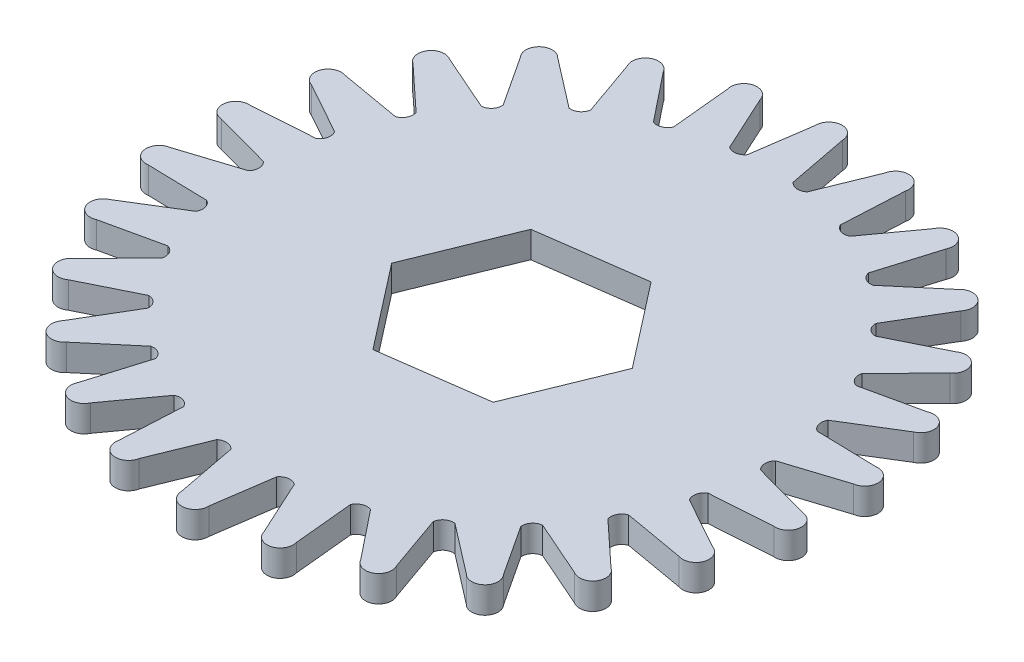
from build123d import *

# Parameters (mm, degrees)
EXTRUDE_1_DEPTH = 2


with BuildPart() as part:
    # Эскиз1 → Бобышка-Вытянуть1 (new body)
    with BuildSketch(Plane(origin=(0, 0, 0), x_dir=(1, 0, 0), z_dir=(0, 1, 0))):
        with BuildLine():
            Line((-0.999103612, 23.957668294), (-1.653583768, 19.471915792))
            ThreePointArc((-1.653583768, 19.471915792), (-2.196840792, 19.142290441), (-2.813399675, 19.29603117))
            Line((-2.813399675, 19.29603117), (-4.78072656, 23.572642625))
            ThreePointArc((-4.78072656, 23.572642625), (-6.018700674, 24.264012159), (-6.703516779, 23.02240085))
            Line((-6.703516779, 23.02240085), (-6.265468091, 18.51036881))
            ThreePointArc((-6.265468091, 18.51036881), (-6.714054544, 18.060311857), (-7.349489911, 18.062032961))
            Line((-7.349489911, 18.062032961), (-10.283109963, 21.743561719))
            ThreePointArc((-10.283109963, 21.743561719), (-11.650566359, 22.118574714), (-12.018345917, 20.749155152))
            Line((-12.018345917, 20.749155152), (-10.513226184, 16.473066476))
            ThreePointArc((-10.513226184, 16.473066476), (-10.841071851, 15.928733595), (-11.458454507, 15.77833505))
            Line((-11.458454507, 15.77833505), (-15.187876393, 18.650824041))
            ThreePointArc((-15.187876393, 18.650824041), (-16.605343475, 18.687686104), (-16.634712476, 17.270043976))
            Line((-16.634712476, 17.270043976), (-14.149993784, 13.478409394))
            ThreePointArc((-14.149993784, 13.478409394), (-14.338045467, 12.871435234), (-14.901495378, 12.577657657))
            Line((-14.901495378, 12.577657657), (-19.209978653, 14.474168263))
            ThreePointArc((-19.209978653, 14.474168263), (-20.595078387, 14.170737105), (-20.28433001, 12.787260619))
            Line((-20.28433001, 12.787260619), (-16.964415179, 9.700436151))
            ThreePointArc((-16.964415179, 9.700436151), (-17.001743998, 9.066095843), (-17.478515502, 8.646012519))
            Line((-17.478515502, 8.646012519), (-22.115666779, 9.456326437))
            ThreePointArc((-22.115666779, 9.456326437), (-23.387902203, 8.830236374), (-22.755096015, 7.561328154))
            Line((-22.755096015, 7.561328154), (-18.792926427, 5.358708819))
            ThreePointArc((-18.792926427, 5.358708819), (-18.677362966, 4.733867916), (-19.039747837, 4.211892561))
            Line((-19.039747837, 4.211892561), (-23.736072739, 3.88891729))
            ThreePointArc((-23.736072739, 3.88891729), (-24.821506154, 2.976554401), (-23.90341855, 1.895958781))
            Line((-23.90341855, 1.895958781), (-19.529261101, 0.705552808))
            ThreePointArc((-19.529261101, 0.705552808), (-19.267521488, 0.126524793), (-19.494459234, -0.467007284))
            Line((-19.494459234, -0.467007284), (-23.977024428, -1.904501593))
            ThreePointArc((-23.977024428, -1.904501593), (-24.81257439, -3.050114094), (-23.662561285, -3.879596824))
            Line((-23.662561285, -3.879596824), (-19.130626105, -3.988607368))
            ThreePointArc((-19.130626105, -3.988607368), (-18.737921695, -4.488171492), (-18.81622352, -5.118766363))
            Line((-18.81622352, -5.118766363), (-22.824518611, -7.587237767))
            ThreePointArc((-22.824518611, -7.587237767), (-23.361625993, -8.899521045), (-22.046521968, -9.429684364))
            Line((-22.046521968, -9.429684364), (-17.620188657, -8.450964181))
            ThreePointArc((-17.620188657, -8.450964181), (-17.119342004, -8.842031563), (-17.044457289, -9.473041346))
            Line((-17.044457289, -9.473041346), (-20.345534735, -12.82903126))
            ThreePointArc((-20.345534735, -12.82903126), (-20.552984809, -14.231720181), (-19.14921893, -14.431752924))
            Line((-19.14921893, -14.431752924), (-15.085729891, -12.422181675))
            ThreePointArc((-15.085729891, -12.422181675), (-14.505848381, -12.682024899), (-14.282129155, -13.2767776))
            Line((-14.282129155, -13.2767776), (-16.684142334, -17.325248088))
            ThreePointArc((-16.684142334, -17.325248088), (-16.549878855, -18.73682347), (-15.139032892, -18.595100462))
            Line((-15.139032892, -18.595100462), (-11.674543338, -15.671467122))
            ThreePointArc((-11.674543338, -15.671467122), (-11.049327577, -15.784985046), (-10.689775588, -16.308915799))
            Line((-10.689775588, -16.308915799), (-12.053128225, -20.814584472))
            ThreePointArc((-12.053128225, -20.814584472), (-11.584954098, -22.153010685), (-10.249021291, -21.677768351))
            Line((-10.249021291, -21.677768351), (-7.584874762, -18.009983863))
            ThreePointArc((-7.584874762, -18.009983863), (-6.950660017, -17.970579237), (-6.476171119, -18.393239092))
            Line((-6.476171119, -18.393239092), (-6.721630115, -23.094252864))
            ThreePointArc((-6.721630115, -23.094252864), (-5.946753919, -24.281745441), (-4.763373826, -23.500603139))
            Line((-4.763373826, -23.500603139), (-3.054400834, -19.301825806))
            ThreePointArc((-3.054400834, -19.301825806), (-2.448045361, -19.111788684), (-1.886195124, -19.408614185))
            Line((-1.886195124, -19.408614185), (-0.999495294, -24.031767224))
            ThreePointArc((-0.999495294, -24.031767224), (0.037049983, -24.999313414), (0.999103612, -23.957668294))
            Line((0.999103612, -23.957668294), (1.653583768, -19.471915792))
            ThreePointArc((1.653583768, -19.471915792), (2.196840792, -19.142290441), (2.813399675, -19.29603117))
            Line((2.813399675, -19.29603117), (4.78072656, -23.572642625))
            ThreePointArc((4.78072656, -23.572642625), (6.018700674, -24.264012159), (6.703516779, -23.02240085))
            Line((6.703516779, -23.02240085), (6.265468091, -18.51036881))
            ThreePointArc((6.265468091, -18.51036881), (6.714054544, -18.060311857), (7.349489911, -18.062032961))
            Line((7.349489911, -18.062032961), (10.283109963, -21.743561719))
            ThreePointArc((10.283109963, -21.743561719), (11.650566359, -22.118574714), (12.018345917, -20.749155152))
            Line((12.018345917, -20.749155152), (10.513226184, -16.473066476))
            ThreePointArc((10.513226184, -16.473066476), (10.841071851, -15.928733595), (11.458454507, -15.77833505))
            Line((11.458454507, -15.77833505), (15.187876393, -18.650824041))
            ThreePointArc((15.187876393, -18.650824041), (16.605343475, -18.687686104), (16.634712476, -17.270043976))
            Line((16.634712476, -17.270043976), (14.149993784, -13.478409394))
            ThreePointArc((14.149993784, -13.478409394), (14.338045467, -12.871435234), (14.901495378, -12.577657657))
            Line((14.901495378, -12.577657657), (19.209978653, -14.474168263))
            ThreePointArc((19.209978653, -14.474168263), (20.595078387, -14.170737105), (20.28433001, -12.787260619))
            Line((20.28433001, -12.787260619), (16.964415179, -9.700436151))
            ThreePointArc((16.964415179, -9.700436151), (17.001743998, -9.066095843), (17.478515502, -8.646012519))
            Line((17.478515502, -8.646012519), (22.115666779, -9.456326437))
            ThreePointArc((22.115666779, -9.456326437), (23.387902203, -8.830236374), (22.755096015, -7.561328154))
            Line((22.755096015, -7.561328154), (18.792926427, -5.358708819))
            ThreePointArc((18.792926427, -5.358708819), (18.677362966, -4.733867916), (19.039747837, -4.211892561))
            Line((19.039747837, -4.211892561), (23.736072739, -3.88891729))
            ThreePointArc((23.736072739, -3.88891729), (24.821506154, -2.976554401), (23.90341855, -1.895958781))
            Line((23.90341855, -1.895958781), (19.529261101, -0.705552808))
            ThreePointArc((19.529261101, -0.705552808), (19.267521488, -0.126524793), (19.494459234, 0.467007284))
            Line((19.494459234, 0.467007284), (23.977024428, 1.904501593))
            ThreePointArc((23.977024428, 1.904501593), (24.81257439, 3.050114094), (23.662561285, 3.879596824))
            Line((23.662561285, 3.879596824), (19.130626105, 3.988607368))
            ThreePointArc((19.130626105, 3.988607368), (18.737921695, 4.488171492), (18.81622352, 5.118766363))
            Line((18.81622352, 5.118766363), (22.824518611, 7.587237767))
            ThreePointArc((22.824518611, 7.587237767), (23.361625993, 8.899521045), (22.046521968, 9.429684364))
            Line((22.046521968, 9.429684364), (17.620188657, 8.450964181))
            ThreePointArc((17.620188657, 8.450964181), (17.119342004, 8.842031563), (17.044457289, 9.473041346))
            Line((17.044457289, 9.473041346), (20.345534735, 12.82903126))
            ThreePointArc((20.345534735, 12.82903126), (20.552984809, 14.231720181), (19.14921893, 14.431752924))
            Line((19.14921893, 14.431752924), (15.085729891, 12.422181675))
            ThreePointArc((15.085729891, 12.422181675), (14.505848381, 12.682024899), (14.282129155, 13.2767776))
            Line((14.282129155, 13.2767776), (16.684142334, 17.325248088))
            ThreePointArc((16.684142334, 17.325248088), (16.549878855, 18.73682347), (15.139032892, 18.595100462))
            Line((15.139032892, 18.595100462), (11.674543338, 15.671467122))
            ThreePointArc((11.674543338, 15.671467122), (11.049327577, 15.784985046), (10.689775588, 16.308915799))
            Line((10.689775588, 16.308915799), (12.053128225, 20.814584472))
            ThreePointArc((12.053128225, 20.814584472), (11.584954098, 22.153010685), (10.249021291, 21.677768351))
            Line((10.249021291, 21.677768351), (7.584874762, 18.009983863))
            ThreePointArc((7.584874762, 18.009983863), (6.950660017, 17.970579237), (6.476171119, 18.393239092))
            Line((6.476171119, 18.393239092), (6.721630115, 23.094252864))
            ThreePointArc((6.721630115, 23.094252864), (5.946753919, 24.281745441), (4.763373826, 23.500603139))
            Line((4.763373826, 23.500603139), (3.054400834, 19.301825806))
            ThreePointArc((3.054400834, 19.301825806), (2.448045361, 19.111788684), (1.886195124, 19.408614185))
            Line((1.886195124, 19.408614185), (0.999495294, 24.031767224))
            ThreePointArc((0.999495294, 24.031767224), (-0.037049983, 24.999313414), (-0.999103612, 23.957668294))
        make_face()
        Polygon((4.960496045, -6.38175621), (8.007011021, 1.105037486), (3.046514976, 7.486793695), (-4.960496045, 6.38175621), (-8.007011021, -1.105037486), (-3.046514976, -7.486793695), align=None, mode=Mode.SUBTRACT)
    extrude(amount=EXTRUDE_1_DEPTH)


solid = part.part
